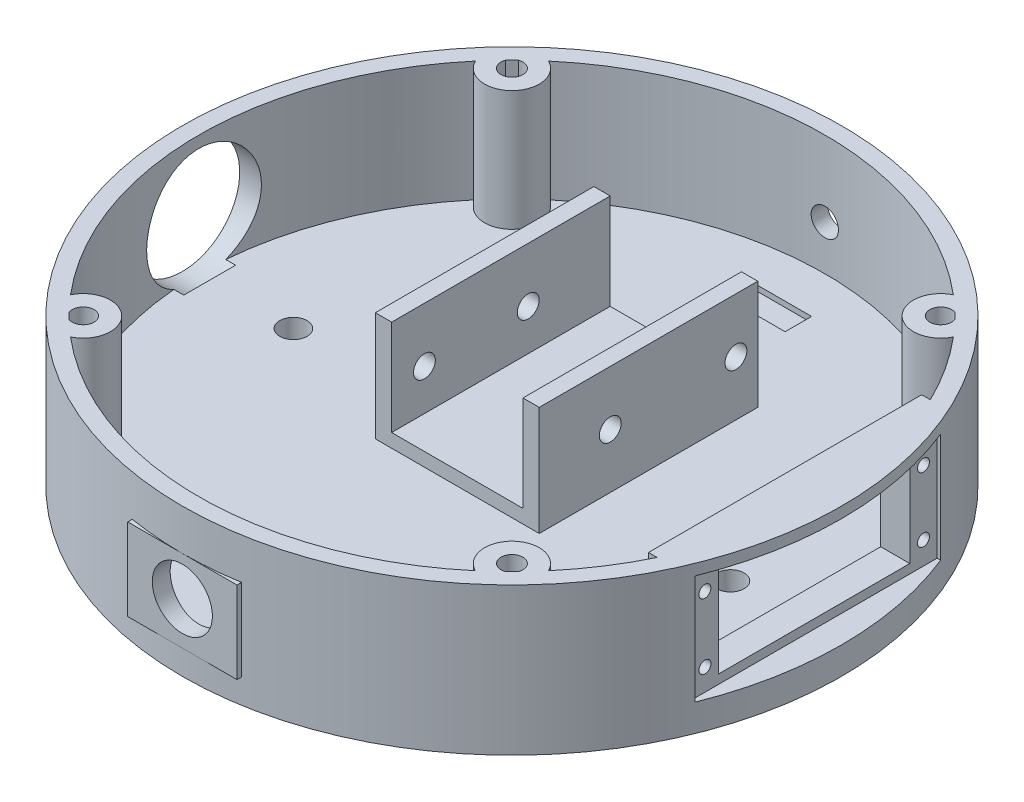
from build123d import *

# Parameters (mm, degrees)
SKETCH1_R            = 60.325
BOSS_EXTRUDE1_DEPTH  = 5
SKETCH2_W            = 30
SKETCH2_H            = 40
BOSS_EXTRUDE2_DEPTH  = 20
SKETCH3_R            = 60.325
SKETCH3_R_2          = 57.325
BOSS_EXTRUDE3_DEPTH  = 22
SKETCH6_W            = 20
SKETCH6_H            = 15
BOSS_EXTRUDE13_DEPTH = 2
SKETCH7_R            = 5.5
CUT_EXTRUDE1_DEPTH   = 5
SKETCH8_W            = 24.036843194
SKETCH8_H            = 20
CUT_EXTRUDE2_DEPTH   = 50
SKETCH11_R           = 2
CUT_EXTRUDE5_DEPTH   = 20
SKETCH12_R           = 2
CUT_EXTRUDE6_DEPTH   = 20
SKETCH14_R           = 2.5
CUT_EXTRUDE7_DEPTH   = 5
SKETCH15_R           = 12.5
BOSS_EXTRUDE15_DEPTH = 3
SKETCH16_R           = 10.5
CUT_EXTRUDE9_DEPTH   = 5
SKETCH17_R           = 2.5
CUT_EXTRUDE10_DEPTH  = 5
SKETCH20_W           = 10.617189632
SKETCH20_H           = 4.842928604
CUT_EXTRUDE13_DEPTH  = 1
SKETCH26_W           = 50
SKETCH26_H           = 22
BOSS_EXTRUDE46_DEPTH = 10
SKETCH27_W           = 45
SKETCH27_H           = 20
CUT_EXTRUDE15_DEPTH  = 5
SKETCH29_R           = 1.1
CUT_EXTRUDE17_DEPTH  = 10
SKETCH28_W           = 35
SKETCH28_H           = 16.696250362
CUT_EXTRUDE18_DEPTH  = 20
BOSS_EXTRUDE47_DEPTH = 22
CUT_EXTRUDE19_DEPTH  = 30


with BuildPart() as part:
    # Sketch1 → Boss-Extrude1 (new body)
    with BuildSketch(Plane(origin=(0, 0, 0), x_dir=(1, 0, 0), z_dir=(0, 1, 0))):
        Circle(SKETCH1_R)
    extrude(amount=BOSS_EXTRUDE1_DEPTH)

    # Sketch2 → Boss-Extrude2 (add)
    with BuildSketch(Plane(origin=(0, 5, 0), x_dir=(1, 0, 0), z_dir=(0, 1, 0))):
        with Locations((0, 10)):
            Rectangle(SKETCH2_W, SKETCH2_H)
    extrude(amount=BOSS_EXTRUDE2_DEPTH)

    # Sketch3 → Boss-Extrude3 (add)
    with BuildSketch(Plane(origin=(0, 5, 0), x_dir=(1, 0, 0), z_dir=(0, 1, 0))):
        Circle(SKETCH3_R)
        Circle(SKETCH3_R_2, mode=Mode.SUBTRACT)
    extrude(amount=BOSS_EXTRUDE3_DEPTH)

    # Sketch6 → Boss-Extrude13 (add)
    with BuildSketch(Plane.XY.offset(60.325)):
        with Locations((0, 12)):
            Rectangle(SKETCH6_W, SKETCH6_H)
    extrude(amount=-BOSS_EXTRUDE13_DEPTH)

    # Sketch7 → Cut-Extrude1 (cut)
    with BuildSketch(Plane.XY.offset(60.325)):
        with Locations((0, 12.313384582)):
            Circle(SKETCH7_R)
    extrude(amount=-CUT_EXTRUDE1_DEPTH, mode=Mode.SUBTRACT)

    # Sketch8 → Cut-Extrude2 (cut)
    with BuildSketch(Plane.XY.offset(10)):
        with Locations((0, 17.5)):
            Rectangle(SKETCH8_W, SKETCH8_H)
    extrude(amount=-CUT_EXTRUDE2_DEPTH, mode=Mode.SUBTRACT)

    # Sketch11 → Cut-Extrude5 (cut)
    with BuildSketch(Plane.ZY.offset(15)):
        with Locations((-15, 15)):
            Circle(SKETCH11_R)
        with Locations((4, 15)):
            Circle(SKETCH11_R)
    extrude(amount=-CUT_EXTRUDE5_DEPTH, mode=Mode.SUBTRACT)

    # Sketch12 → Cut-Extrude6 (cut)
    with BuildSketch(Plane(origin=(15, 0, 0), x_dir=(0, 0, -1), z_dir=(1, 0, 0))):
        with Locations((3, 15)):
            Circle(SKETCH12_R)
        with Locations((26, 15)):
            Circle(SKETCH12_R)
    extrude(amount=-CUT_EXTRUDE6_DEPTH, mode=Mode.SUBTRACT)

    # Sketch14 → Cut-Extrude7 (cut)
    with BuildSketch(Plane(origin=(0, 0, -60.325), x_dir=(-1, 0, 0), z_dir=(0, 0, -1))):
        with Locations((0, 13.215899789)):
            Circle(SKETCH14_R)
    extrude(amount=-CUT_EXTRUDE7_DEPTH, mode=Mode.SUBTRACT)

    # Sketch15 → Boss-Extrude15 (add)
    with BuildSketch(Plane.ZY.offset(60.325)):
        with Locations((0, 14.079498946)):
            Circle(SKETCH15_R)
    extrude(amount=-BOSS_EXTRUDE15_DEPTH)

    # Sketch16 → Cut-Extrude9 (cut)
    with BuildSketch(Plane.ZY.offset(60.325)):
        with Locations((0, 14.367365331)):
            Circle(SKETCH16_R)
    extrude(amount=-CUT_EXTRUDE9_DEPTH, mode=Mode.SUBTRACT)

    # Sketch17 → Cut-Extrude10 (cut)
    with BuildSketch(Plane(origin=(0, 5, 0), x_dir=(1, 0, 0), z_dir=(0, 1, 0))):
        with Locations((0, 40)):
            Circle(SKETCH17_R)
        with Locations((40, 0)):
            Circle(SKETCH17_R)
        with Locations((0, -40)):
            Circle(SKETCH17_R)
        with Locations((-40, 0)):
            Circle(SKETCH17_R)
    extrude(amount=-CUT_EXTRUDE10_DEPTH, mode=Mode.SUBTRACT)

    # Sketch20 → Cut-Extrude13 (cut)
    with BuildSketch(Plane(origin=(0, 5, 0), x_dir=(1, 0, 0), z_dir=(0, 1, 0))):
        with Locations((0.203305294, 46.911797789)):
            Rectangle(SKETCH20_W, SKETCH20_H)
    extrude(amount=-CUT_EXTRUDE13_DEPTH, mode=Mode.SUBTRACT)

    # Sketch26 → Boss-Extrude46 (add)
    with BuildSketch(Plane(origin=(50, 0, 0), x_dir=(0, 0, -1), z_dir=(1, 0, 0))):
        with Locations((0, 16)):
            Rectangle(SKETCH26_W, SKETCH26_H)
    extrude(amount=BOSS_EXTRUDE46_DEPTH)

    # Sketch27 → Cut-Extrude15 (cut)
    with BuildSketch(Plane(origin=(60.325, 0, 0), x_dir=(0, 0, -1), z_dir=(1, 0, 0))):
        with Locations((0, 15)):
            Rectangle(SKETCH27_W, SKETCH27_H)
    extrude(amount=-CUT_EXTRUDE15_DEPTH, mode=Mode.SUBTRACT)

    # Sketch29 → Cut-Extrude17 (cut)
    with BuildSketch(Plane(origin=(55.325, 0, 0), x_dir=(0, 0, -1), z_dir=(1, 0, 0))):
        with Locations((-20, 21)):
            Circle(SKETCH29_R)
        with Locations((-20, 9)):
            Circle(SKETCH29_R)
        with Locations((20, 21)):
            Circle(SKETCH29_R)
        with Locations((20, 9.151874819)):
            Circle(SKETCH29_R)
    extrude(amount=-CUT_EXTRUDE17_DEPTH, mode=Mode.SUBTRACT)

    # Sketch28 → Cut-Extrude18 (cut)
    with BuildSketch(Plane(origin=(60.325, 0, 0), x_dir=(0, 0, -1), z_dir=(1, 0, 0))):
        with Locations((0, 15)):
            Rectangle(SKETCH28_W, SKETCH28_H)
    extrude(amount=-CUT_EXTRUDE18_DEPTH, mode=Mode.SUBTRACT)

    # Sketch5 → Boss-Extrude47 (add)
    with BuildSketch(Plane(origin=(0, 5, 0), x_dir=(1, 0, 0), z_dir=(0, 1, 0))):
        with BuildLine():
            ThreePointArc((-43.739295545, 37.054414719), (-40.07067607, 34.313167753), (-35.70889245, 35.70889245))
            Line((-35.70889245, 35.70889245), (-37.830212793, 37.830212793))
            ThreePointArc((-37.830212793, 37.830212793), (-40.32541, 37.56172782), (-41.11857325, 39.942690932))
            ThreePointArc((-41.11857325, 39.942690932), (-42.453504084, 38.520846512), (-43.739295545, 37.054414719))
        make_face()
        with BuildLine():
            Line((-37.830212793, 37.830212793), (-35.70889245, 35.70889245))
            ThreePointArc((-35.70889245, 35.70889245), (-34.625028693, 37.331009194), (-34.244426356, 39.244426356))
            ThreePointArc((-34.244426356, 39.244426356), (-35.00472954, 41.894892524), (-37.054414719, 43.739295545))
            ThreePointArc((-37.054414719, 43.739295545), (-38.520846512, 42.453504084), (-39.942690932, 41.11857325))
            ThreePointArc((-39.942690932, 41.11857325), (-38.103490151, 40.887065871), (-37.244426356, 39.244426356))
            ThreePointArc((-37.244426356, 39.244426356), (-37.396667291, 38.479059491), (-37.830212793, 37.830212793))
        make_face()
        with BuildLine():
            ThreePointArc((-34.244426356, -39.244426356), (-34.625028693, -37.331009194), (-35.70889245, -35.70889245))
            Line((-35.70889245, -35.70889245), (-37.830212793, -37.830212793))
            ThreePointArc((-37.830212793, -37.830212793), (-37.396667291, -38.479059491), (-37.244426356, -39.244426356))
            ThreePointArc((-37.244426356, -39.244426356), (-38.103490151, -40.887065871), (-39.942690932, -41.11857325))
            ThreePointArc((-39.942690932, -41.11857325), (-38.520846512, -42.453504084), (-37.054414719, -43.739295545))
            ThreePointArc((-37.054414719, -43.739295545), (-35.00472954, -41.894892524), (-34.244426356, -39.244426356))
        make_face()
        with BuildLine():
            Line((-37.830212793, -37.830212793), (-35.70889245, -35.70889245))
            ThreePointArc((-35.70889245, -35.70889245), (-40.07067607, -34.313167753), (-43.739295545, -37.054414719))
            ThreePointArc((-43.739295545, -37.054414719), (-42.453504084, -38.520846512), (-41.11857325, -39.942690932))
            ThreePointArc((-41.11857325, -39.942690932), (-40.32541, -37.56172782), (-37.830212793, -37.830212793))
        make_face()
        with BuildLine():
            ThreePointArc((43.739295545, -37.054414719), (40.07067607, -34.313167753), (35.70889245, -35.70889245))
            Line((35.70889245, -35.70889245), (37.830212793, -37.830212793))
            ThreePointArc((37.830212793, -37.830212793), (40.009793221, -37.396667291), (41.244426356, -39.244426356))
            ThreePointArc((41.244426356, -39.244426356), (41.212711623, -39.599184168), (41.11857325, -39.942690932))
            ThreePointArc((41.11857325, -39.942690932), (42.453504084, -38.520846512), (43.739295545, -37.054414719))
        make_face()
        with BuildLine():
            Line((37.830212793, -37.830212793), (35.70889245, -35.70889245))
            ThreePointArc((35.70889245, -35.70889245), (34.313167753, -40.07067607), (37.054414719, -43.739295545))
            ThreePointArc((37.054414719, -43.739295545), (38.520846512, -42.453504084), (39.942690932, -41.11857325))
            ThreePointArc((39.942690932, -41.11857325), (37.56172782, -40.32541), (37.830212793, -37.830212793))
        make_face()
        with BuildLine():
            ThreePointArc((37.054414719, 43.739295545), (34.313167753, 40.07067607), (35.70889245, 35.70889245))
            Line((35.70889245, 35.70889245), (37.830212793, 37.830212793))
            ThreePointArc((37.830212793, 37.830212793), (37.56172782, 40.32541), (39.942690932, 41.11857325))
            ThreePointArc((39.942690932, 41.11857325), (38.520846512, 42.453504084), (37.054414719, 43.739295545))
        make_face()
        with BuildLine():
            Line((37.830212793, 37.830212793), (35.70889245, 35.70889245))
            ThreePointArc((35.70889245, 35.70889245), (40.07067607, 34.313167753), (43.739295545, 37.054414719))
            ThreePointArc((43.739295545, 37.054414719), (42.453504084, 38.520846512), (41.11857325, 39.942690932))
            ThreePointArc((41.11857325, 39.942690932), (41.212711623, 39.599184168), (41.244426356, 39.244426356))
            ThreePointArc((41.244426356, 39.244426356), (40.009793221, 37.396667291), (37.830212793, 37.830212793))
        make_face()
    extrude(amount=BOSS_EXTRUDE47_DEPTH)

    # Sketch30 → Cut-Extrude19 (cut)
    with BuildSketch(Plane(origin=(0, 27, 0), x_dir=(1, 0, 0), z_dir=(0, 1, 0))):
        with BuildLine():
            Line((51.783140737, 30.945305952), (68.409720281, 30.945305952))
            ThreePointArc((68.409720281, 30.945305952), (75.079003763, -0.803108545), (67.732108243, -32.401594133))
            Line((67.732108243, -32.401594133), (50.884598089, -32.401594133))
            ThreePointArc((50.884598089, -32.401594133), (60.318932239, -0.855592508), (51.783140737, 30.945305952))
        make_face()
    extrude(amount=-CUT_EXTRUDE19_DEPTH, mode=Mode.SUBTRACT)


solid = part.part
